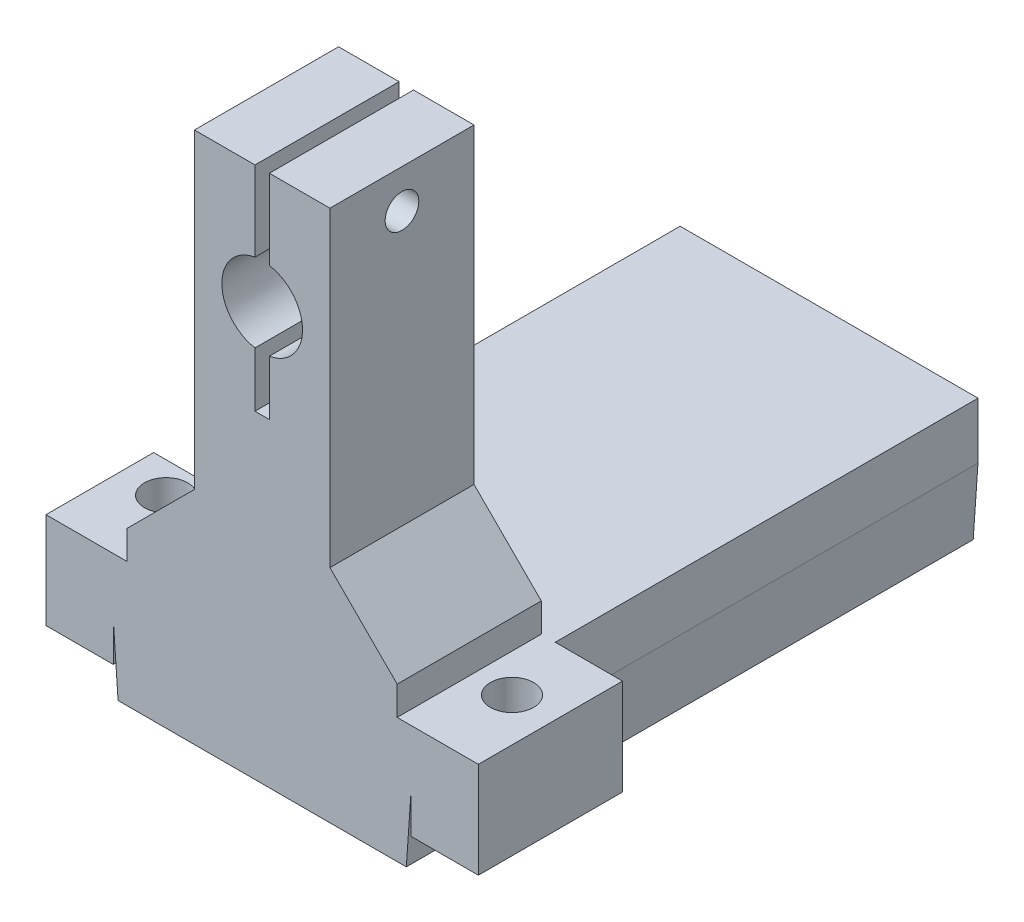
from build123d import *

# Parameters (mm, degrees)
SKETCH1_W                = 26
SKETCH1_H                = 53
SKETCH1_W_2              = 20
SKETCH1_H_2              = 10
BOSS_EXTRUDE1_DEPTH      = 5
SKETCH2_W                = 31
SKETCH2_H                = 59
SKETCH2_W_2              = 26
SKETCH2_H_2              = 53
BOSS_EXTRUDE2_DEPTH      = 10
SKETCH3_W                = 31
SKETCH3_H                = 59
BOSS_EXTRUDE3_DEPTH      = 3
CHAMFER1_SIZE            = 0.5
CHAMFER1_SIZE2           = 7.150333128
SKETCH10_W               = 7
SKETCH10_H               = 15
SKETCH10_R               = 2.25
BOSS_EXTRUDE7_DEPTH      = 10
BOSS_EXTRUDE9_DEPTH      = 3
BOSS_EXTRUDE9_DEPTH_BACK = 12
SKETCH12_R               = 1.75
CUT_EXTRUDE4_DEPTH       = 30.54863335
SKETCH13_W               = 7
SKETCH13_H               = 3.8
CUT_EXTRUDE5_DEPTH       = 10


with BuildPart() as part:
    # Sketch1 → Boss-Extrude1 (new body)
    with BuildSketch(Plane(origin=(0, 0, 0), x_dir=(1, 0, 0), z_dir=(0, 1, 0))):
        with Locations((-13, 26.5)):
            Rectangle(SKETCH1_W, SKETCH1_H)
        with Locations((-13, 27)):
            Rectangle(SKETCH1_W_2, SKETCH1_H_2, mode=Mode.SUBTRACT)
        with Locations((-13, 43)):
            Rectangle(SKETCH1_W_2, SKETCH1_H_2, mode=Mode.SUBTRACT)
        with Locations((-13, 11)):
            Rectangle(SKETCH1_W_2, SKETCH1_H_2, mode=Mode.SUBTRACT)
    extrude(amount=BOSS_EXTRUDE1_DEPTH)

    # Sketch2 → Boss-Extrude2 (add)
    with BuildSketch(Plane(origin=(0, 5, 0), x_dir=(1, 0, 0), z_dir=(0, 1, 0))):
        with Locations((-13, 26.5)):
            Rectangle(SKETCH2_W, SKETCH2_H)
        with Locations((-13, 26.5)):
            Rectangle(SKETCH2_W_2, SKETCH2_H_2, mode=Mode.SUBTRACT)
    extrude(amount=-BOSS_EXTRUDE2_DEPTH)

    # Sketch3 → Boss-Extrude3 (add)
    with BuildSketch(Plane(origin=(0, 5, 0), x_dir=(1, 0, 0), z_dir=(0, 1, 0))):
        with Locations((-13, 26.5)):
            Rectangle(SKETCH3_W, SKETCH3_H)
    extrude(amount=BOSS_EXTRUDE3_DEPTH)

    # Chamfer1
    chamfer1_edges = [part.edges().sort_by_distance(p)[0] for p in [
        (-28.5, -5, -26.5),
        (2.5, -5, -26.5),
    ]]
    chamfer1_side = [part.faces().sort_by_distance(p)[0] for p in [
        (-13, -5, -55.333516692),
    ]]
    chamfer(chamfer1_edges, length=CHAMFER1_SIZE, length2=CHAMFER1_SIZE2, reference=chamfer1_side[0])

    # Sketch10 → Boss-Extrude7 (add)
    with BuildSketch(Plane(origin=(0, 8, 0), x_dir=(1, 0, 0), z_dir=(0, 1, 0))):
        with Locations((6, 4.5)):
            Rectangle(SKETCH10_W, SKETCH10_H)
        with Locations((5, 5)):
            Circle(SKETCH10_R, mode=Mode.SUBTRACT)
        with Locations((-32, 4.5)):
            Rectangle(SKETCH10_W, SKETCH10_H)
        with Locations((-31, 5)):
            Circle(SKETCH10_R, mode=Mode.SUBTRACT)
    extrude(amount=-BOSS_EXTRUDE7_DEPTH)

    # Sketch11 → Boss-Extrude9 (add, two sides)
    with BuildSketch(Plane.XY) as boss_extrude9_sk:
        with BuildLine():
            Line((-13.74863335, 28.198986818), (-12.25136665, 28.198986818))
            Line((-12.25136665, 28.198986818), (-12.25136665, 33.909462138))
            ThreePointArc((-12.25136665, 33.909462138), (-8.80136665, 38), (-12.25136665, 42.090537862))
            Line((-12.25136665, 42.090537862), (-12.25136665, 50.4))
            Line((-12.25136665, 50.4), (-5.95136665, 50.4))
            Line((-5.95136665, 50.4), (-5.95136665, 18))
            Line((-5.95136665, 18), (1.04863335, 11))
            Line((1.04863335, 11), (1.04863335, 8))
            Line((1.04863335, 8), (-27.04863335, 8))
            Line((-27.04863335, 8), (-27.04863335, 11))
            Line((-27.04863335, 11), (-20.04863335, 18))
            Line((-20.04863335, 18), (-20.04863335, 50.4))
            Line((-20.04863335, 50.4), (-13.74863335, 50.4))
            Line((-13.74863335, 50.4), (-13.74863335, 42.090537862))
            ThreePointArc((-13.74863335, 42.090537862), (-17.19863335, 38), (-13.74863335, 33.909462138))
            Line((-13.74863335, 33.909462138), (-13.74863335, 28.198986818))
        make_face()
    extrude(amount=BOSS_EXTRUDE9_DEPTH)
    extrude(boss_extrude9_sk.sketch, amount=-BOSS_EXTRUDE9_DEPTH_BACK)

    # Sketch12 → Cut-Extrude4 (cut, through all)
    with BuildSketch(Plane(origin=(-5.95136665, 0, 0), x_dir=(0, 0, -1), z_dir=(1, 0, 0))):
        with Locations((4.5, 46.4)):
            Circle(SKETCH12_R)
    extrude(amount=-CUT_EXTRUDE4_DEPTH, mode=Mode.SUBTRACT)

    # Sketch13 → Cut-Extrude5 (cut)
    with BuildSketch(Plane(origin=(0, 8, 0), x_dir=(1, 0, 0), z_dir=(0, 1, 0))):
        with Locations((-32, 10.1)):
            Rectangle(SKETCH13_W, SKETCH13_H)
    extrude(amount=-CUT_EXTRUDE5_DEPTH, mode=Mode.SUBTRACT)


solid = part.part
